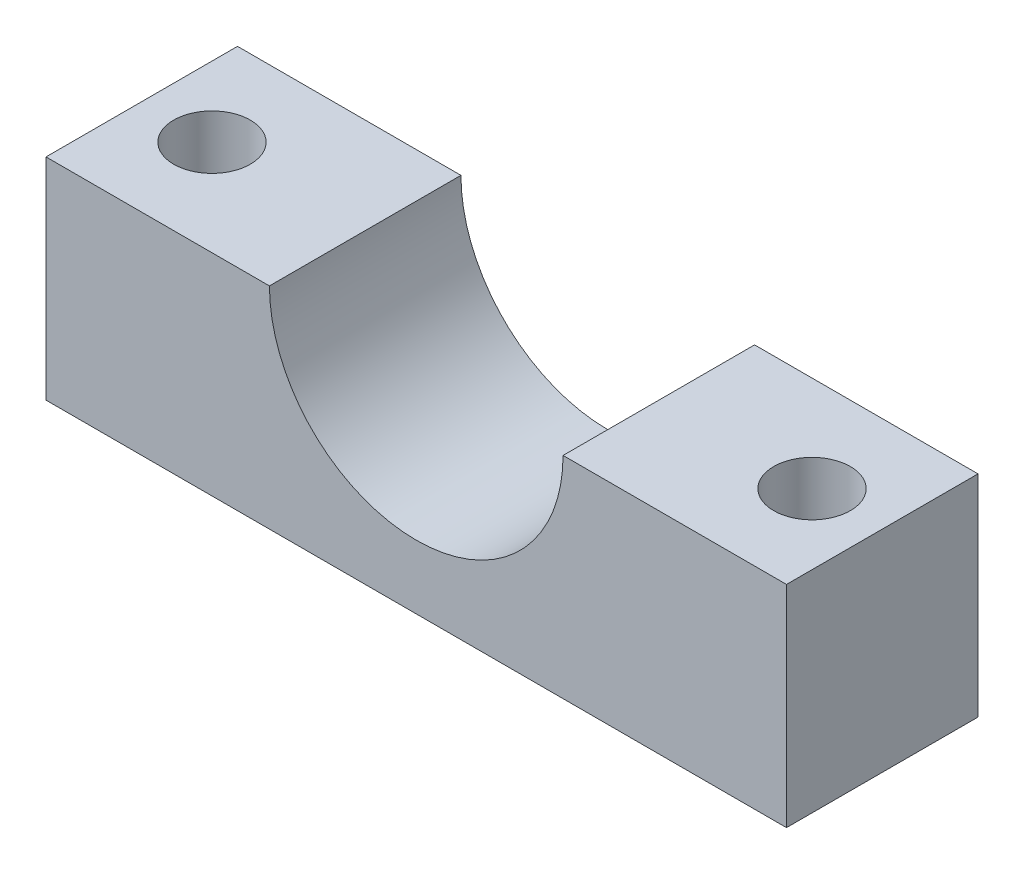
from build123d import *

# Parameters (mm, degrees)
DODANIE_WYCI_GNI_CIE1_DEPTH = 15


with BuildPart() as part:
    # Szkic1 → Dodanie-wyciągnięcie1 (new body)
    with BuildSketch(Plane.XY):
        with BuildLine():
            Line((-11.5, 0), (-29, 0))
            Line((-29, 0), (-29, -16.5))
            Line((-29, -16.5), (29, -16.5))
            Line((29, -16.5), (29, 0))
            Line((29, 0), (11.5, 0))
            ThreePointArc((11.5, 0), (0, -11.5), (-11.5, 0))
        make_face()
    extrude(amount=DODANIE_WYCI_GNI_CIE1_DEPTH)

    # Szkic3 → Otwory ustalające Ø6.0mm1 (revolve, cut)
    with BuildSketch(Plane(origin=(-23.5, 0, 7.5), x_dir=(0, 0, 1), z_dir=(1, 0, 0))):
        Polygon((0, 0), (0, 11.802581857), (3, 10), (3, 0), align=None)
    otwory_ustalaj_ce_6_0mm1 = revolve(axis=Axis((-23.5, 6.35, 7.5), (0, -1, 0)), mode=Mode.SUBTRACT)

    # Lustro1: Otwory ustalające Ø6.0mm1 across plane
    add(otwory_ustalaj_ce_6_0mm1.mirror(Plane(origin=(0, 0, 0), x_dir=(0, 0, 1), z_dir=(1, 0, 0))), mode=Mode.SUBTRACT)


solid = part.part
